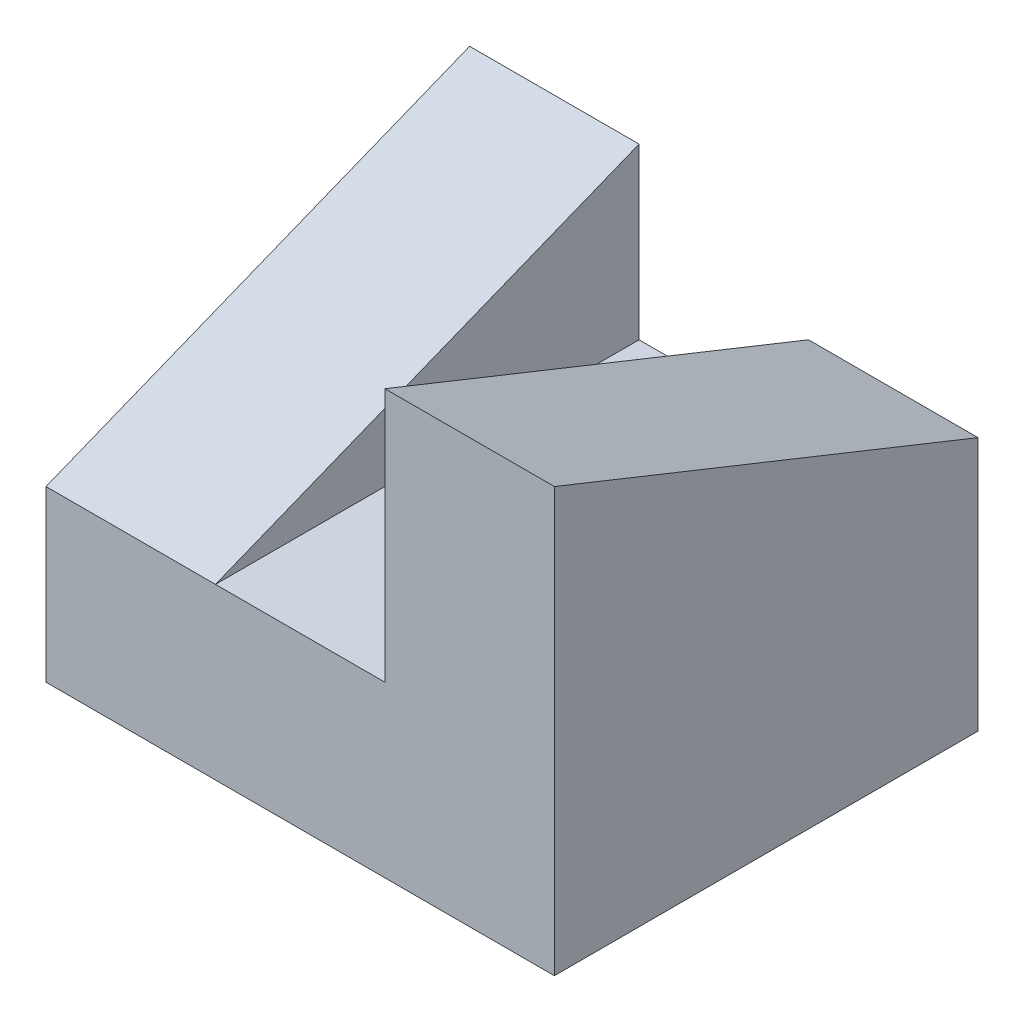
from build123d import *

# Parameters (mm, degrees)
BOSS_EXTRUDE1_DEPTH = 25
BOSS_EXTRUDE2_DEPTH = 10
BOSS_EXTRUDE3_DEPTH = 10


with BuildPart() as part:
    # Sketch1 → Boss-Extrude1 (new body)
    with BuildSketch(Plane.XY):
        Polygon((-30, 10), (-10, 10), (-10, 15), (0, 15), (0, 0), (-30, 0), align=None)
    extrude(amount=BOSS_EXTRUDE1_DEPTH)

    # Sketch2 → Boss-Extrude2 (add)
    with BuildSketch(Plane.ZY.offset(30)):
        Polygon((0, 10), (0, 20), (25, 10), align=None)
    extrude(amount=-BOSS_EXTRUDE2_DEPTH)

    # Sketch3 → Boss-Extrude3 (add)
    with BuildSketch(Plane(origin=(0, 0, 0), x_dir=(0, 0, -1), z_dir=(1, 0, 0))):
        Polygon((-25, 15), (-25, 25), (0, 15), align=None)
    extrude(amount=-BOSS_EXTRUDE3_DEPTH)


solid = part.part
